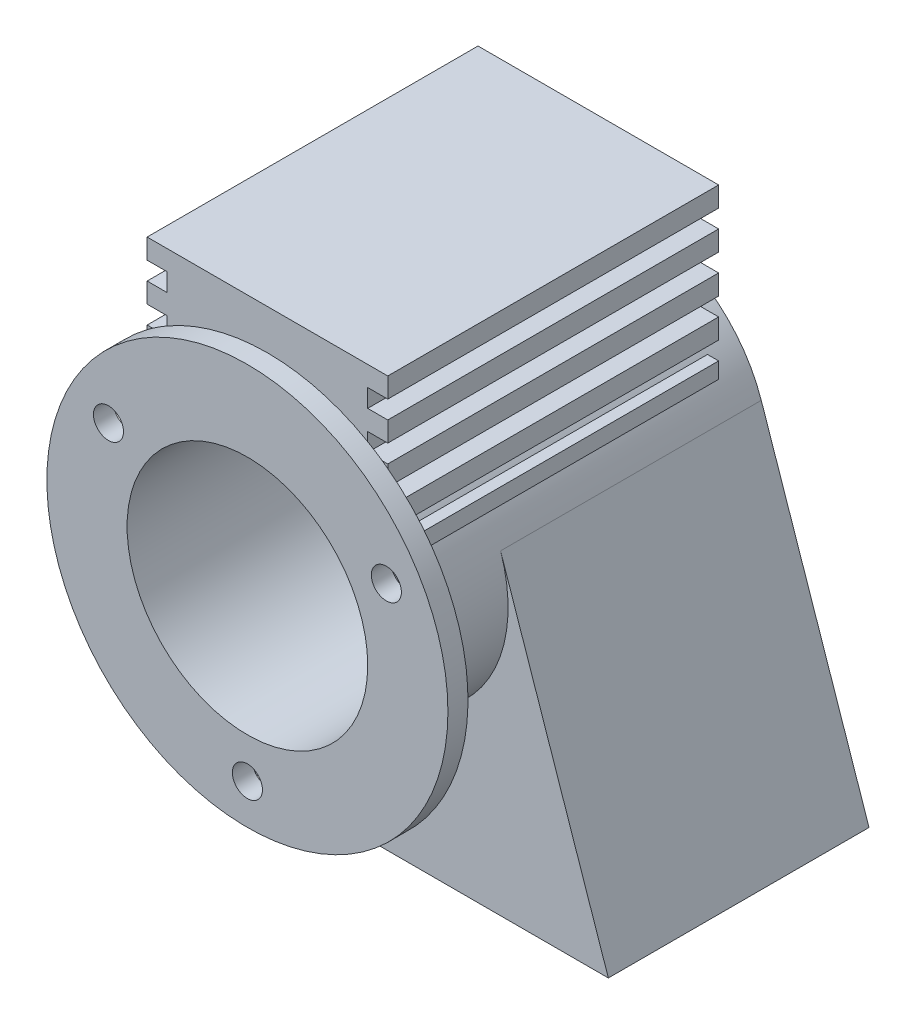
from build123d import *

# Parameters (mm, degrees)
SKETCH1_R           = 0.75
BOSS_EXTRUDE1_DEPTH = 6.5
SKETCH6_R           = 3.5
BOSS_EXTRUDE4_DEPTH = 2.5
SKETCH7_R           = 5
BOSS_EXTRUDE5_DEPTH = 0.5
SKETCH8_R           = 0.75
CUT_EXTRUDE1_DEPTH  = 3
BOSS_EXTRUDE6_START = 2.5
BOSS_EXTRUDE6_DEPTH = 8.25
CUT_EXTRUDE2_REACH  = 11.5
SKETCH11_R          = 0.375
CUT_EXTRUDE3_START  = 3
SKETCH13_R          = 3
CUT_EXTRUDE3_DEPTH  = 8.5


with BuildPart() as part:
    # Sketch1 → Boss-Extrude1 (new body)
    with BuildSketch(Plane.XY):
        with BuildLine():
            Line((-6, -6.75), (6, -6.75))
            Line((6, -6.75), (3.312648335, 1.129761483))
            ThreePointArc((3.312648335, 1.129761483), (0, 3.5), (-3.312648335, 1.129761483))
            Line((-3.312648335, 1.129761483), (-6, -6.75))
        make_face()
        Circle(SKETCH1_R, mode=Mode.SUBTRACT)
    extrude(amount=-BOSS_EXTRUDE1_DEPTH)

    # Sketch6 → Boss-Extrude4 (add)
    with BuildSketch(Plane.XY):
        Circle(SKETCH6_R)
    extrude(amount=BOSS_EXTRUDE4_DEPTH)

    # Sketch7 → Boss-Extrude5 (add)
    with BuildSketch(Plane.XY.offset(2.5)):
        Circle(SKETCH7_R)
    extrude(amount=BOSS_EXTRUDE5_DEPTH)

    # Sketch8 → Cut-Extrude1 (cut)
    with BuildSketch(Plane.XY.offset(3)):
        Circle(SKETCH8_R)
    extrude(amount=-CUT_EXTRUDE1_DEPTH, mode=Mode.SUBTRACT)

    # Sketch10 → Boss-Extrude6 (add)
    with BuildSketch(Plane.XY.offset(BOSS_EXTRUDE6_START)):
        Polygon((-3, 6), (3, 6), (3, 5.5), (2.5, 5.5), (2.5, 5.05), (3, 5.05), (3, 4.55), (2.5, 4.55), (2.5, 4.1), (3, 4.1), (3, 3.6), (2.5, 3.6), (2.5, 3.15), (3, 3.15), (3, 2.65), (2.5, 2.65), (2.5, 2.2), (3, 2.2), (3, 1.7), (-3, 1.7), (-3, 2.2), (-2.5, 2.2), (-2.5, 2.65), (-3, 2.65), (-3, 3.15), (-2.5, 3.15), (-2.5, 3.6), (-3, 3.6), (-3, 4.1), (-2.5, 4.1), (-2.5, 4.55), (-3, 4.55), (-3, 5.05), (-2.5, 5.05), (-2.5, 5.5), (-3, 5.5), align=None)
    extrude(amount=-BOSS_EXTRUDE6_DEPTH)

    # Sketch11 → Cut-Extrude2 (cut, up to next)
    with BuildSketch(Plane.XY.offset(3), mode=Mode.PRIVATE) as cut_extrude2_sk1:
        with Locations((3.464101615, 2)):
            Circle(SKETCH11_R)
    cut_extrude2_tool1 = extrude(cut_extrude2_sk1.sketch, amount=-CUT_EXTRUDE2_REACH, mode=Mode.PRIVATE) & part.part
    add(cut_extrude2_tool1.solids().sort_by_distance((3.464102, 2, 3))[0], mode=Mode.SUBTRACT)
    # Sketch11 → Cut-Extrude2 (cut, up to next)
    with BuildSketch(Plane.XY.offset(3), mode=Mode.PRIVATE) as cut_extrude2_sk2:
        with Locations((0, -4)):
            Circle(SKETCH11_R)
    cut_extrude2_tool2 = extrude(cut_extrude2_sk2.sketch, amount=-CUT_EXTRUDE2_REACH, mode=Mode.PRIVATE) & part.part
    add(cut_extrude2_tool2.solids().sort_by_distance((0, -4, 3))[0], mode=Mode.SUBTRACT)
    # Sketch11 → Cut-Extrude2 (cut, up to next)
    with BuildSketch(Plane.XY.offset(3), mode=Mode.PRIVATE) as cut_extrude2_sk3:
        with Locations((-3.464101615, 2)):
            Circle(SKETCH11_R)
    cut_extrude2_tool3 = extrude(cut_extrude2_sk3.sketch, amount=-CUT_EXTRUDE2_REACH, mode=Mode.PRIVATE) & part.part
    add(cut_extrude2_tool3.solids().sort_by_distance((-3.464102, 2, 3))[0], mode=Mode.SUBTRACT)

    # Sketch13 → Cut-Extrude3 (cut)
    with BuildSketch(Plane.XY.offset(CUT_EXTRUDE3_START)):
        Circle(SKETCH13_R)
    extrude(amount=-CUT_EXTRUDE3_DEPTH, mode=Mode.SUBTRACT)


solid = part.part
